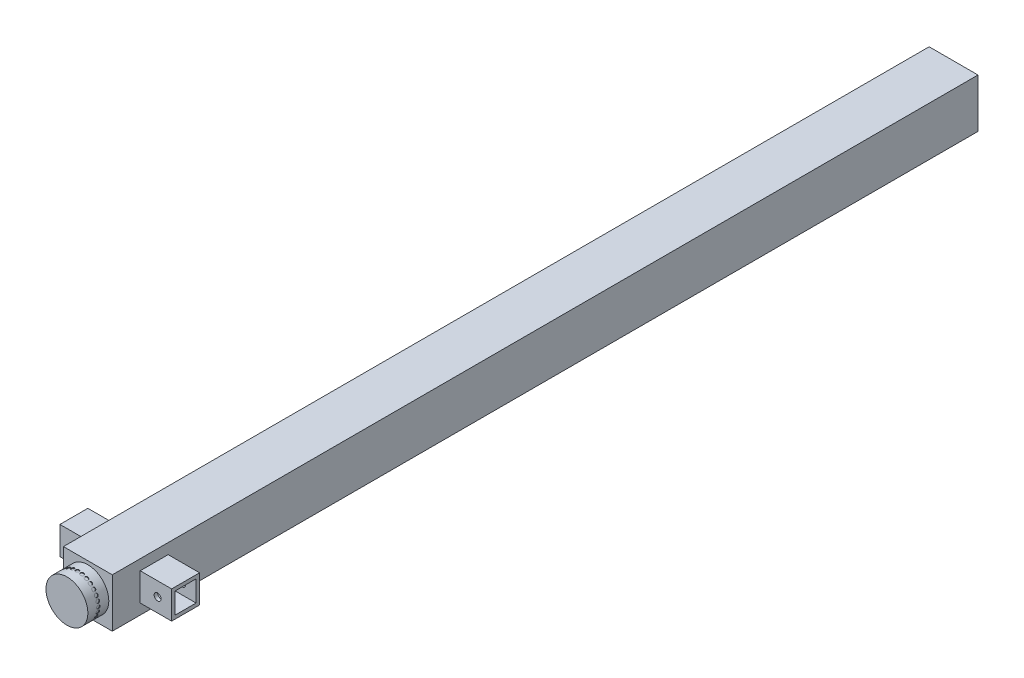
from build123d import *

# Parameters (mm, degrees)
SKETCH1_W           = 88.9
SKETCH1_H           = 88.9
SKETCH1_W_2         = 76.2
SKETCH1_H_2         = 76.2
BOSS_EXTRUDE1_DEPTH = 1574.8
SKETCH2_W           = 88.9
SKETCH2_H           = 6.35
BOSS_EXTRUDE2_DEPTH = 88.9
SKETCH3_R           = 38.1
BOSS_EXTRUDE3_DEPTH = 38.1
SKETCH4_W           = 50.8
SKETCH4_H           = 50.8
SKETCH4_W_2         = 38.1
SKETCH4_H_2         = 38.1
BOSS_EXTRUDE4_DEPTH = 57.15
SKETCH5_W           = 50.8
SKETCH5_H           = 50.8
SKETCH5_W_2         = 38.1
SKETCH5_H_2         = 38.1
BOSS_EXTRUDE5_DEPTH = 57.15
SKETCH7_R           = 3.175
CUT_EXTRUDE1_DEPTH  = 7.62
CRVPATTERN1_COUNT   = 28
CUT_EXTRUDE2_REACH  = 1530.03
SKETCH8_R           = 6.35


with BuildPart() as part:
    # Sketch1 → Boss-Extrude1 (new body)
    with BuildSketch(Plane.XY):
        Rectangle(SKETCH1_W, SKETCH1_H)
        Rectangle(SKETCH1_W_2, SKETCH1_H_2, mode=Mode.SUBTRACT)
    extrude(amount=-BOSS_EXTRUDE1_DEPTH)

    # Sketch2 → Boss-Extrude2 (add)
    with BuildSketch(Plane(origin=(0, 44.45, 0), x_dir=(1, 0, 0), z_dir=(0, 1, 0))):
        with Locations((0, 3.175)):
            Rectangle(SKETCH2_W, SKETCH2_H)
    extrude(amount=-BOSS_EXTRUDE2_DEPTH)

    # Sketch3 → Boss-Extrude3 (add)
    with BuildSketch(Plane.XY):
        with Locations(Location((0, 0, 0), (0, 0, 180))):
            Circle(SKETCH3_R)
    extrude(amount=BOSS_EXTRUDE3_DEPTH)

    # Sketch4 → Boss-Extrude4 (add)
    with BuildSketch(Plane(origin=(44.45, 0, 0), x_dir=(0, 0, -1), z_dir=(1, 0, 0))):
        with Locations((76.2, 0)):
            Rectangle(SKETCH4_W, SKETCH4_H)
        with Locations((76.2, 0)):
            Rectangle(SKETCH4_W_2, SKETCH4_H_2, mode=Mode.SUBTRACT)
    extrude(amount=BOSS_EXTRUDE4_DEPTH)

    # Sketch5 → Boss-Extrude5 (add)
    with BuildSketch(Plane.ZY.offset(44.45)):
        with Locations((-76.2, 0)):
            Rectangle(SKETCH5_W, SKETCH5_H)
        with Locations((-76.2, 0)):
            Rectangle(SKETCH5_W_2, SKETCH5_H_2, mode=Mode.SUBTRACT)
    extrude(amount=BOSS_EXTRUDE5_DEPTH)

    # Sketch7 → Cut-Extrude1 (cut)
    with BuildSketch(Plane.ZY.offset(44.45)):
        with Locations(Location((19.05, 0, 0), (0, 0, 270))):
            Circle(SKETCH7_R)
    cut_extrude1 = extrude(amount=-CUT_EXTRUDE1_DEPTH, mode=Mode.SUBTRACT)

    # CrvPattern1: Cut-Extrude1 ×28 about axis
    crvpattern1_axis = Axis((0, 0, 38.1), (0, 0, 1))
    for i in range(1, CRVPATTERN1_COUNT):
        add(cut_extrude1.rotate(crvpattern1_axis, i * 360 / CRVPATTERN1_COUNT), mode=Mode.SUBTRACT)

    # Cut-Extrude2: up to this face of the body (flat: up to its plane)
    cut_extrude2_end = Plane(part.part.faces().sort_by_distance((-73.025, 0, -101.6))[0])
    # Sketch8 → Cut-Extrude2 (cut, up to the picked face)
    with BuildSketch(Plane.XY.offset(-50.8), mode=Mode.PRIVATE) as cut_extrude2_sk1:
        with Locations((-76.2, 0)):
            Circle(SKETCH8_R)
    cut_extrude2_tool1 = split(extrude(cut_extrude2_sk1.sketch, amount=-CUT_EXTRUDE2_REACH, mode=Mode.PRIVATE), bisect_by=cut_extrude2_end, keep=Keep.BOTH, mode=Mode.PRIVATE)
    # Sketch8 → Cut-Extrude2 (cut, up to the picked face)
    with BuildSketch(Plane.XY.offset(-50.8), mode=Mode.PRIVATE) as cut_extrude2_sk2:
        with Locations((76.2, 0)):
            Circle(SKETCH8_R)
    cut_extrude2_tool2 = split(extrude(cut_extrude2_sk2.sketch, amount=-CUT_EXTRUDE2_REACH, mode=Mode.PRIVATE), bisect_by=cut_extrude2_end, keep=Keep.BOTH, mode=Mode.PRIVATE)
    add(cut_extrude2_tool1.solids().sort_by(Axis((-76.2, 0, -50.8), (0, 0, -1)))[0], mode=Mode.SUBTRACT)
    add(cut_extrude2_tool2.solids().sort_by(Axis((76.2, 0, -50.8), (0, 0, -1)))[0], mode=Mode.SUBTRACT)


solid = part.part
